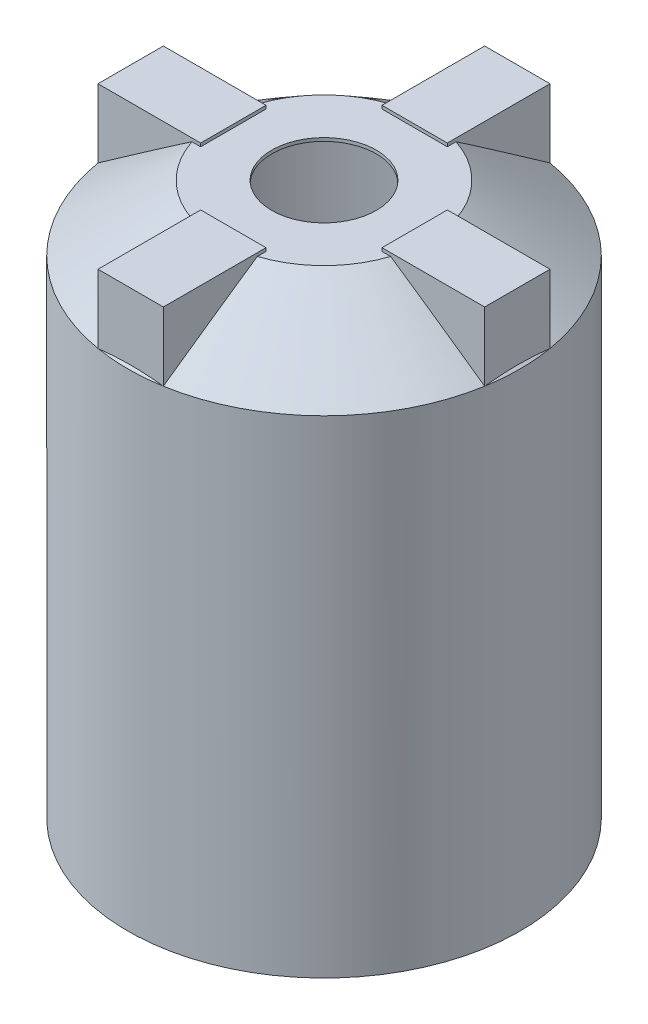
from build123d import *

# Parameters (mm, degrees)
SKETCH1_R           = 381
SKETCH1_R_2         = 374.65
BOSS_EXTRUDE1_DEPTH = 1066.8
SKETCH4_W           = 127
SKETCH4_H           = 203.2
SKETCH4_W_2         = 203.2
SKETCH4_H_2         = 127
CUT_EXTRUDE7_DEPTH  = 127
SKETCH6_W           = 203.2
SKETCH6_H           = 127
SKETCH6_W_2         = 183.106953235
SKETCH6_H_2         = 114.441845772
SKETCH6_W_3         = 127
SKETCH6_H_3         = 203.2
SKETCH6_W_4         = 114.441845772
SKETCH6_H_4         = 183.106953235
BOSS_EXTRUDE3_DEPTH = 127
SKETCH7_W           = 199.503476618
SKETCH7_H           = 127
SKETCH7_W_2         = 127
SKETCH7_H_2         = 199.503476618
BOSS_EXTRUDE4_DEPTH = 6.35
SKETCH8_R           = 381
BOSS_EXTRUDE5_DEPTH = 6.35


with BuildPart() as part:
    # Sketch1 → Boss-Extrude1 (new body)
    with BuildSketch(Plane(origin=(0, 0, 0), x_dir=(1, 0, 0), z_dir=(0, 1, 0))):
        Circle(SKETCH1_R)
        Circle(SKETCH1_R_2, mode=Mode.SUBTRACT)
    extrude(amount=BOSS_EXTRUDE1_DEPTH)

    # Sketch3 → Revolve1 (revolve)
    with BuildSketch(Plane.XY):
        Polygon((203.2, 1066.8), (381, 939.8), (381, 931.996462079), (201.165046911, 1060.45), (101.6, 1060.45), (101.6, 1066.8), align=None)
    revolve(axis=Axis((0, 1066.8, 0), (0, -1, 0)))

    # Sketch5 → Cut-Revolve2 (revolve, cut)
    with BuildSketch(Plane.XY):
        Polygon((203.2, 1066.8), (381, 939.8), (381, 1066.8), align=None)
    revolve(axis=Axis((0, 0, 0), (0, 1, 0)), mode=Mode.SUBTRACT)

    # Sketch4 → Cut-Extrude7 (cut)
    with BuildSketch(Plane(origin=(0, 1066.8, 0), x_dir=(1, 0, 0), z_dir=(0, 1, 0))):
        with Locations((0, -274.071066227)):
            Rectangle(SKETCH4_W, SKETCH4_H)
        with Locations((274.071066227, 0)):
            Rectangle(SKETCH4_W_2, SKETCH4_H_2)
        with Locations((-274.071066227, 0)):
            Rectangle(SKETCH4_W_2, SKETCH4_H_2)
        with Locations((0, 274.071066227)):
            Rectangle(SKETCH4_W, SKETCH4_H)
    extrude(amount=-CUT_EXTRUDE7_DEPTH, mode=Mode.SUBTRACT)

    # Sketch6 → Boss-Extrude3 (add)
    with BuildSketch(Plane(origin=(0, 1066.8, 0), x_dir=(1, 0, 0), z_dir=(0, 1, 0))):
        with Locations((274.071066227, 0)):
            Rectangle(SKETCH6_W, SKETCH6_H)
        with Locations((274.071066227, 0)):
            Rectangle(SKETCH6_W_2, SKETCH6_H_2, mode=Mode.SUBTRACT)
        with Locations((0, -274.071066227)):
            Rectangle(SKETCH6_W_3, SKETCH6_H_3)
        with Locations((0, -274.071066227)):
            Rectangle(SKETCH6_W_4, SKETCH6_H_4, mode=Mode.SUBTRACT)
        with Locations((-274.071066227, 0)):
            Rectangle(SKETCH6_W, SKETCH6_H)
        with Locations((-274.071066227, 0)):
            Rectangle(SKETCH6_W_2, SKETCH6_H_2, mode=Mode.SUBTRACT)
        with Locations((0, 274.071066227)):
            Rectangle(SKETCH6_W_3, SKETCH6_H_3)
        with Locations((0, 274.071066227)):
            Rectangle(SKETCH6_W_4, SKETCH6_H_4, mode=Mode.SUBTRACT)
    extrude(amount=-BOSS_EXTRUDE3_DEPTH)

    # Sketch7 → Boss-Extrude4 (add)
    with BuildSketch(Plane(origin=(0, 1066.8, 0), x_dir=(1, 0, 0), z_dir=(0, 1, 0))):
        with Locations((275.919327918, 0)):
            Rectangle(SKETCH7_W, SKETCH7_H)
        with Locations((0, -275.919327918)):
            Rectangle(SKETCH7_W_2, SKETCH7_H_2)
        with Locations((-275.919327918, 0)):
            Rectangle(SKETCH7_W, SKETCH7_H)
        with Locations((0, 275.919327918)):
            Rectangle(SKETCH7_W_2, SKETCH7_H_2)
    extrude(amount=BOSS_EXTRUDE4_DEPTH)

    # Sketch8 → Boss-Extrude5 (add)
    with BuildSketch(Plane.XZ):
        Circle(SKETCH8_R)
    extrude(amount=BOSS_EXTRUDE5_DEPTH)

    # Sketch9 → Cut-Revolve3 (revolve, cut)
    with BuildSketch(Plane.XY):
        Polygon((172.471066227, 1060.45), (374.65, 936.532176365), (172.471066227, 936.532176365), align=None)
    revolve(axis=Axis((0, 0, 0), (0, 1, 0)), mode=Mode.SUBTRACT)


solid = part.part
